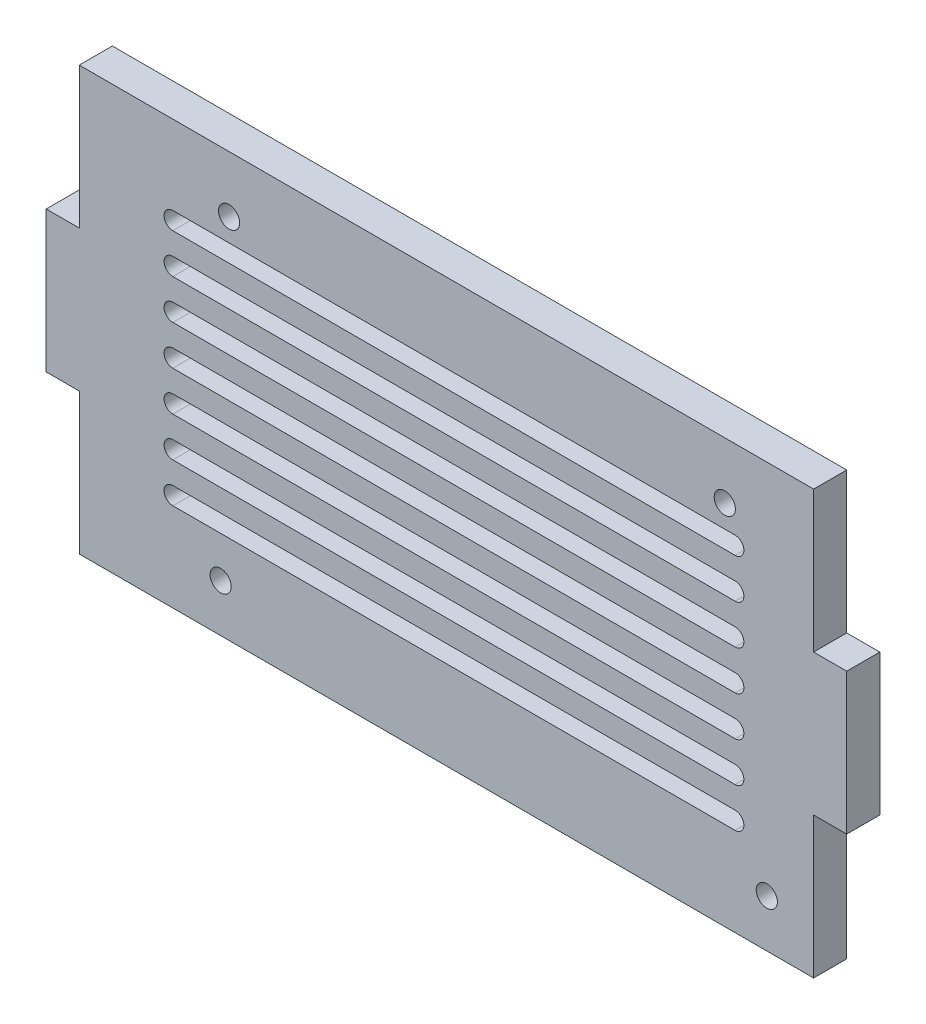
from build123d import *

# Parameters (mm, degrees)
CROQUIS1_W              = 111
CROQUIS1_H              = 64
CROQUIS1_R              = 1.6
SALIENTE_EXTRUIR1_DEPTH = 5
CROQUIS2_W              = 5
CROQUIS2_H              = 21.3333333
SALIENTE_EXTRUIR2_DEPTH = 5
CROQUIS3_W              = 5
CROQUIS3_H              = 21.3333333
SALIENTE_EXTRUIR3_DEPTH = 5


with BuildPart() as part:
    # Croquis1 → Saliente-Extruir1 (new body)
    with BuildSketch(Plane.XY):
        with Locations((13.812375919, -5.640074375)):
            Rectangle(CROQUIS1_W, CROQUIS1_H)
        with Locations((-20.317624082, -30.440068587)):
            Circle(CROQUIS1_R, mode=Mode.SUBTRACT)
        with Locations((-19.047624082, 17.819931413)):
            Circle(CROQUIS1_R, mode=Mode.SUBTRACT)
        with Locations((55.882375918, 17.819931413)):
            Circle(CROQUIS1_R, mode=Mode.SUBTRACT)
        with Locations((62.232375918, -30.440068587)):
            Circle(CROQUIS1_R, mode=Mode.SUBTRACT)
        with BuildLine():
            Line((-27.547897963, 14.398218547), (57.441208347, 14.398218547))
            ThreePointArc((57.441208347, 14.398218547), (58.7657139, 13.073712995), (57.441208347, 11.749207442))
            Line((57.441208347, 11.749207442), (-27.547897963, 11.749207442))
            ThreePointArc((-27.547897963, 11.749207442), (-28.872403516, 13.073712995), (-27.547897963, 14.398218547))
        make_face(mode=Mode.SUBTRACT)
        with BuildLine():
            Line((-27.547897963, 8.398218547), (57.441208347, 8.398218547))
            ThreePointArc((57.441208347, 8.398218547), (58.7657139, 7.073712995), (57.441208347, 5.749207442))
            Line((57.441208347, 5.749207442), (-27.547897963, 5.749207442))
            ThreePointArc((-27.547897963, 5.749207442), (-28.872403516, 7.073712995), (-27.547897963, 8.398218547))
        make_face(mode=Mode.SUBTRACT)
        with BuildLine():
            Line((-27.547897963, 2.398218547), (57.441208347, 2.398218547))
            ThreePointArc((57.441208347, 2.398218547), (58.7657139, 1.073712995), (57.441208347, -0.250792558))
            Line((57.441208347, -0.250792558), (-27.547897963, -0.250792558))
            ThreePointArc((-27.547897963, -0.250792558), (-28.872403516, 1.073712995), (-27.547897963, 2.398218547))
        make_face(mode=Mode.SUBTRACT)
        with BuildLine():
            Line((-27.547897963, -3.601781453), (57.441208347, -3.601781453))
            ThreePointArc((57.441208347, -3.601781453), (58.7657139, -4.926287005), (57.441208347, -6.250792558))
            Line((57.441208347, -6.250792558), (-27.547897963, -6.250792558))
            ThreePointArc((-27.547897963, -6.250792558), (-28.872403516, -4.926287005), (-27.547897963, -3.601781453))
        make_face(mode=Mode.SUBTRACT)
        with BuildLine():
            Line((-27.547897963, -9.601781453), (57.441208347, -9.601781453))
            ThreePointArc((57.441208347, -9.601781453), (58.7657139, -10.926287005), (57.441208347, -12.250792558))
            Line((57.441208347, -12.250792558), (-27.547897963, -12.250792558))
            ThreePointArc((-27.547897963, -12.250792558), (-28.872403516, -10.926287005), (-27.547897963, -9.601781453))
        make_face(mode=Mode.SUBTRACT)
        with BuildLine():
            Line((-27.547897963, -15.601781453), (57.441208347, -15.601781453))
            ThreePointArc((57.441208347, -15.601781453), (58.7657139, -16.926287005), (57.441208347, -18.250792558))
            Line((57.441208347, -18.250792558), (-27.547897963, -18.250792558))
            ThreePointArc((-27.547897963, -18.250792558), (-28.872403516, -16.926287005), (-27.547897963, -15.601781453))
        make_face(mode=Mode.SUBTRACT)
        with BuildLine():
            Line((-27.547897963, -21.601781453), (57.441208347, -21.601781453))
            ThreePointArc((57.441208347, -21.601781453), (58.7657139, -22.926287005), (57.441208347, -24.250792558))
            Line((57.441208347, -24.250792558), (-27.547897963, -24.250792558))
            ThreePointArc((-27.547897963, -24.250792558), (-28.872403516, -22.926287005), (-27.547897963, -21.601781453))
        make_face(mode=Mode.SUBTRACT)
    extrude(amount=SALIENTE_EXTRUIR1_DEPTH)

    # Croquis2 → Saliente-Extruir2 (add)
    with BuildSketch(Plane.ZY.offset(41.687624081)):
        with Locations((2.5, -5.640074358)):
            Rectangle(CROQUIS2_W, CROQUIS2_H)
    extrude(amount=SALIENTE_EXTRUIR2_DEPTH)

    # Croquis3 → Saliente-Extruir3 (add)
    with BuildSketch(Plane(origin=(69.312375919, 0, 0), x_dir=(0, 0, -1), z_dir=(1, 0, 0))):
        with Locations((-2.5, -5.640074358)):
            Rectangle(CROQUIS3_W, CROQUIS3_H)
    extrude(amount=SALIENTE_EXTRUIR3_DEPTH)


solid = part.part
